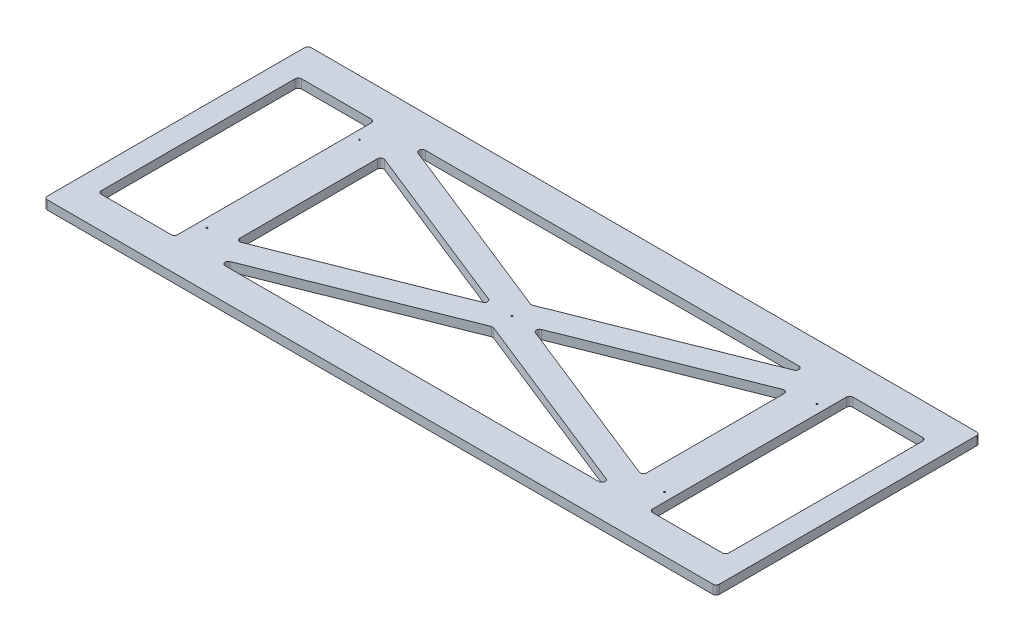
from build123d import *

# Parameters (mm, degrees)
SKETCH1_W                    = 1343.025
SKETCH1_H                    = 527.05
BOSS_EXTRUDE1_DEPTH          = 17.78
FILLET1_R                    = 6.35
F_1_8_0_125_DIAMETER_HOLE1_D = 3.175
SKETCH5_W                    = 152.4
SKETCH5_H                    = 400.05
CUT_EXTRUDE1_DEPTH           = 18.78
FILLET2_R                    = 6.35


with BuildPart() as part:
    # Sketch1 → Boss-Extrude1 (new body)
    with BuildSketch(Plane(origin=(0, 0, 0), x_dir=(1, 0, 0), z_dir=(0, 1, 0))):
        Rectangle(SKETCH1_W, SKETCH1_H)
    extrude(amount=BOSS_EXTRUDE1_DEPTH)

    # Fillet1
    fillet1_edges = [part.edges().sort_by_distance(p)[0] for p in [
        (671.5125, 8.89, 263.525),
        (-671.5125, 8.89, 263.525),
        (-671.5125, 8.89, -263.525),
        (671.5125, 8.89, -263.525),
    ]]
    fillet(fillet1_edges, radius=FILLET1_R)

    # 1/8 (0.125) Diameter Hole1 (through all)
    with Locations(Plane(origin=(0, 17.78, 0), x_dir=(1, 0, 0), z_dir=(0, 1, 0))):
        with Locations((0, 0), (457.2, 152.4), (-457.2, -152.4), (-457.2, 152.4), (457.2, -152.4)):
            Hole(F_1_8_0_125_DIAMETER_HOLE1_D / 2)

    # Sketch5 → Cut-Extrude1 (cut, through all)
    with BuildSketch(Plane(origin=(0, 17.78, 0), x_dir=(1, 0, 0), z_dir=(0, 1, 0))):
        Polygon((-406.4, 200.025), (406.4, 200.025), (0, 38.1), align=None)
        Polygon((0, -38.1), (-406.4, -200.025), (406.4, -200.025), align=None)
        Polygon((406.4, 146.74453125), (406.4, -146.74453125), (38.1, 0), align=None)
        Polygon((-406.4, 146.74453125), (-38.1, 0), (-406.4, -146.74453125), align=None)
        with Locations((550.8625, 0)):
            Rectangle(SKETCH5_W, SKETCH5_H)
        with Locations((-550.8625, 0)):
            Rectangle(SKETCH5_W, SKETCH5_H)
    extrude(amount=-CUT_EXTRUDE1_DEPTH, mode=Mode.SUBTRACT)

    # Fillet2
    fillet2_edges = [part.edges().sort_by_distance(p)[0] for p in [
        (-474.6625, 8.89, -200.025),
        (-474.6625, 8.89, 200.025),
        (-627.0625, 8.89, 200.025),
        (-627.0625, 8.89, -200.025),
        (-406.4, 8.89, 146.74453125),
        (-406.4, 8.89, -146.74453125),
        (-38.1, 8.89, 0),
        (627.0625, 8.89, -200.025),
        (627.0625, 8.89, 200.025),
        (474.6625, 8.89, 200.025),
        (474.6625, 8.89, -200.025),
        (0, 8.89, 38.1),
        (406.4, 8.89, 200.025),
        (-406.4, 8.89, 200.025),
        (38.1, 8.89, 0),
        (406.4, 8.89, -146.74453125),
        (406.4, 8.89, 146.74453125),
        (406.4, 8.89, -200.025),
        (0, 8.89, -38.1),
        (-406.4, 8.89, -200.025),
    ]]
    fillet(fillet2_edges, radius=FILLET2_R)


solid = part.part
